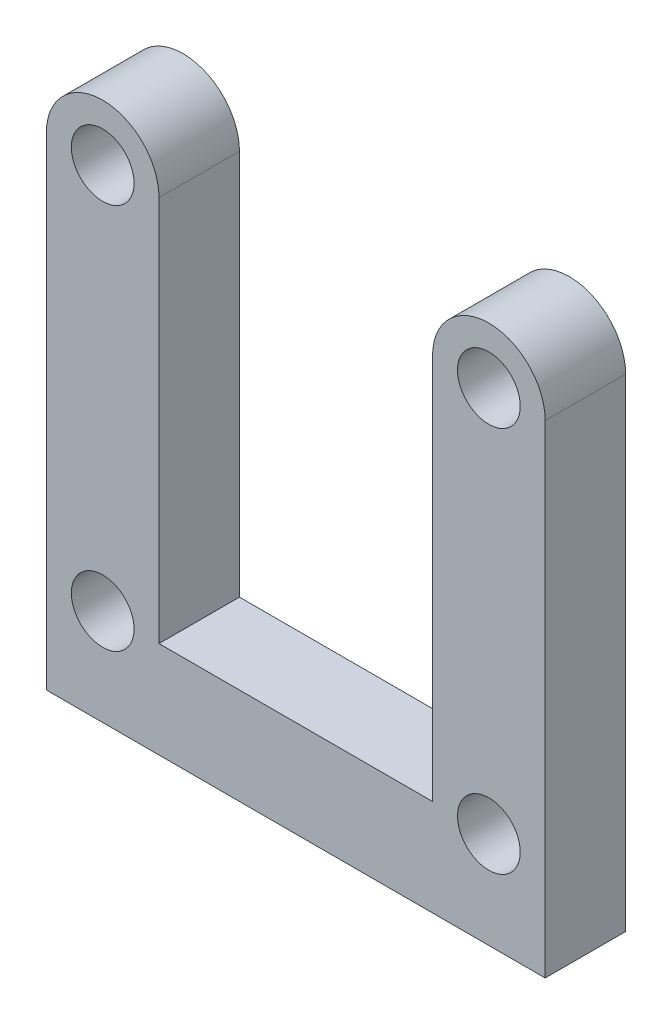
from build123d import *

# Parameters (mm, degrees)
SKETCH1_R           = 1.95
BOSS_EXTRUDE1_DEPTH = 5
SKETCH4_R           = 1.25
CUT_EXTRUDE3_DEPTH  = 5.5


with BuildPart() as part:
    # Sketch1 → Boss-Extrude1 (new body)
    with BuildSketch(Plane.XY):
        with BuildLine():
            ThreePointArc((-8.5, 12), (-12, 15.5), (-15.5, 12))
            Line((-15.5, 12), (-15.5, -12))
            Line((-15.5, -12), (-15.5, -12.97105896))
            Line((-15.5, -12.97105896), (-15.5, -18))
            Line((-15.5, -18), (0, -18))
            Line((0, -18), (15.5, -18))
            Line((15.5, -18), (15.5, -12))
            Line((15.5, -12), (15.5, 12))
            ThreePointArc((15.5, 12), (12, 15.5), (8.5, 12))
            Line((8.5, 12), (8.5, -12))
            Line((8.5, -12), (0, -12))
            Line((0, -12), (-8.5, -12))
            Line((-8.5, -12), (-8.5, 12))
        make_face()
        with Locations((-12, -12)):
            Circle(SKETCH1_R, mode=Mode.SUBTRACT)
        with Locations((12, -12)):
            Circle(SKETCH1_R, mode=Mode.SUBTRACT)
        with Locations((-12, 12)):
            Circle(SKETCH1_R, mode=Mode.SUBTRACT)
        with Locations((12, 12)):
            Circle(SKETCH1_R, mode=Mode.SUBTRACT)
    extrude(amount=BOSS_EXTRUDE1_DEPTH)

    # Sketch4 → Cut-Extrude3 (cut)
    with BuildSketch(Plane.XZ.offset(18)):
        with Locations((-8, 2.5)):
            Circle(SKETCH4_R)
        with Locations((8, 2.5)):
            Circle(SKETCH4_R)
    extrude(amount=-CUT_EXTRUDE3_DEPTH, mode=Mode.SUBTRACT)


solid = part.part
